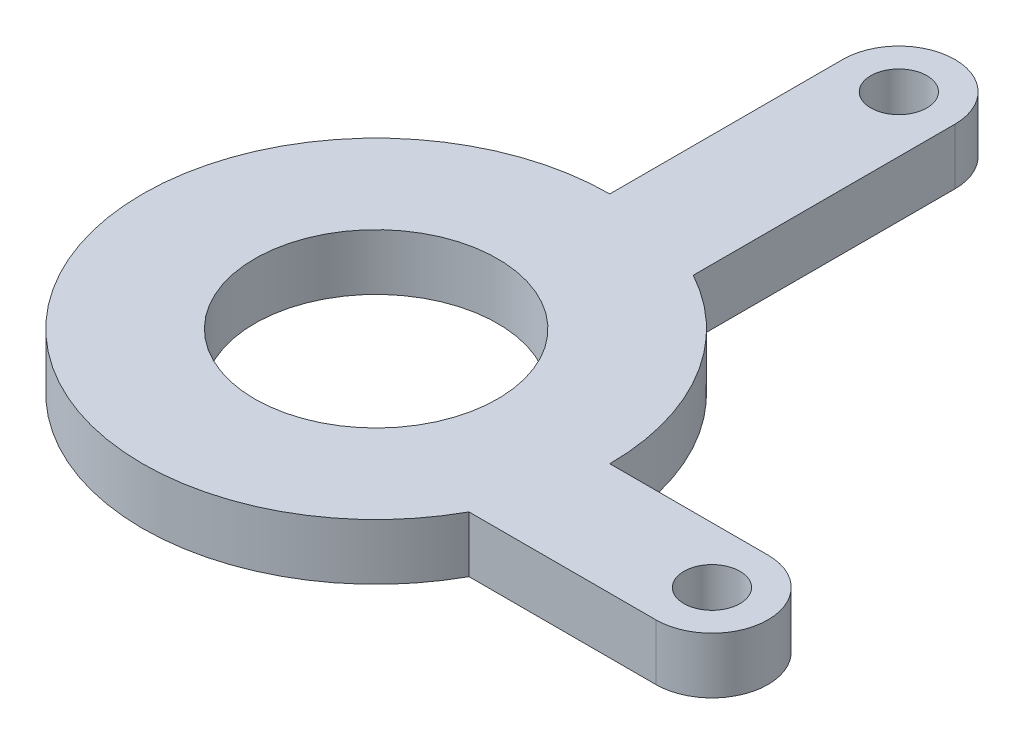
from build123d import *

# Parameters (mm, degrees)
SKETCH1_R           = 6.5
SKETCH1_R_2         = 1.5
BOSS_EXTRUDE1_DEPTH = 3


with BuildPart() as part:
    # Sketch1 → Boss-Extrude1 (new body)
    with BuildSketch(Plane(origin=(0, 0, 0), x_dir=(1, 0, 0), z_dir=(0, 1, 0))):
        with BuildLine():
            Line((0, 12.5), (0, 24.9658561))
            ThreePointArc((0, 24.9658561), (3, 27.9658561), (6, 24.9658561))
            Line((6, 24.9658561), (6, 10.9658561))
            ThreePointArc((6, 10.9658561), (10.752906584, 6.373774392), (12.5, 0))
            Line((12.5, 0), (20.9658561, 0))
            ThreePointArc((20.9658561, 0), (23.9658561, -3), (20.9658561, -6))
            Line((20.9658561, -6), (10.9658561, -6))
            ThreePointArc((10.9658561, -6), (-10.752906584, -6.373774392), (0, 12.5))
        make_face()
        Circle(SKETCH1_R, mode=Mode.SUBTRACT)
        with Locations((3, 24.9658561)):
            Circle(SKETCH1_R_2, mode=Mode.SUBTRACT)
        with Locations((20.9658561, -3)):
            Circle(SKETCH1_R_2, mode=Mode.SUBTRACT)
    extrude(amount=BOSS_EXTRUDE1_DEPTH)


solid = part.part
